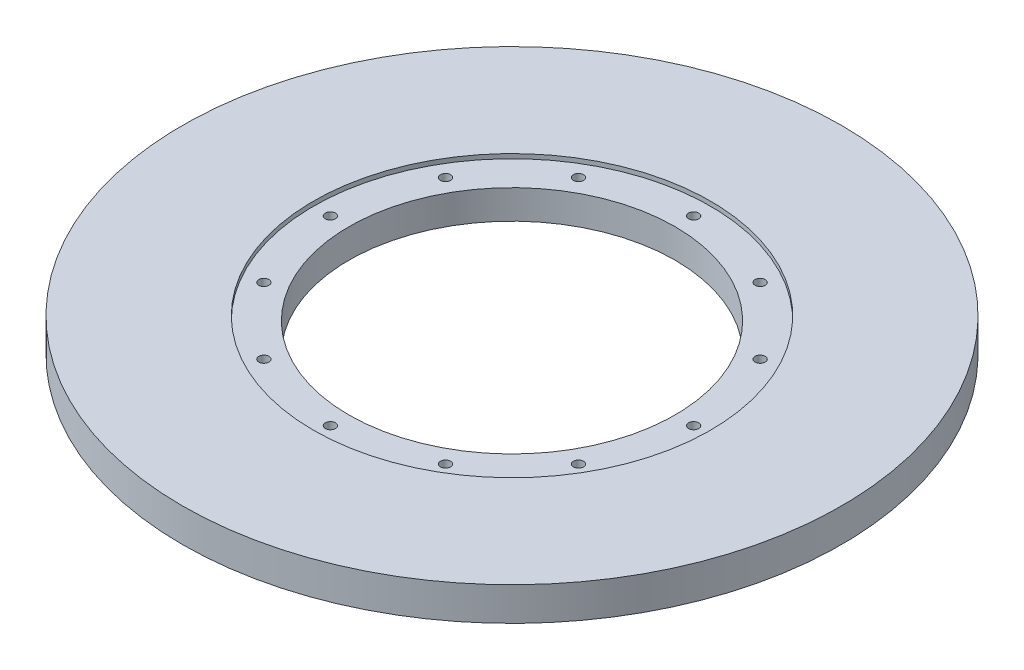
from build123d import *

# Parameters (mm, degrees)
SKETCH1_W           = 127.635
SKETCH1_H           = 127.635
BOSS_EXTRUDE1_DEPTH = 9.525
SKETCH13_R          = 93.6625
BOSS_EXTRUDE2_DEPTH = 9.525
SKETCH6_R           = 1.35255
F_6_32_HOLE1_DEPTH  = 12.7
SKETCH5_R           = 46.355
CUT_EXTRUDE1_DEPTH  = 9.525
SKETCH11_R          = 1.4351
CUT_EXTRUDE3_DEPTH  = 10.525
CIRPATTERN1_COUNT   = 12
SKETCH12_R          = 56.41975
CUT_EXTRUDE4_DEPTH  = 1.27


with BuildPart() as part:
    # Sketch1 → Boss-Extrude1 (new body)
    with BuildSketch(Plane(origin=(0, 0, 0), x_dir=(1, 0, 0), z_dir=(0, 1, 0))):
        with Locations((63.8175, 63.8175)):
            Rectangle(SKETCH1_W, SKETCH1_H)
    extrude(amount=BOSS_EXTRUDE1_DEPTH)

    # Sketch13 → Boss-Extrude2 (add)
    with BuildSketch(Plane(origin=(0, 9.525, 0), x_dir=(1, 0, 0), z_dir=(0, 1, 0))):
        with Locations((63.8175, 63.8175)):
            Circle(SKETCH13_R)
    extrude(amount=-BOSS_EXTRUDE2_DEPTH)

    # Sketch6 → 6-32 hole1 (cut)
    with BuildSketch(Plane(origin=(127.635, 0, 0), x_dir=(0, 0, -1), z_dir=(1, 0, 0))):
        with Locations((4.7625, 4.7625)):
            Circle(SKETCH6_R)
    extrude(amount=-F_6_32_HOLE1_DEPTH, mode=Mode.SUBTRACT)

    # Sketch5 → Cut-Extrude1 (cut)
    with BuildSketch(Plane(origin=(0, 9.525, 0), x_dir=(1, 0, 0), z_dir=(0, 1, 0))):
        with Locations((63.8175, 63.8175)):
            Circle(SKETCH5_R)
    extrude(amount=-CUT_EXTRUDE1_DEPTH, mode=Mode.SUBTRACT)

    # Sketch11 → Cut-Extrude3 (cut, through all)
    with BuildSketch(Plane(origin=(0, 9.525, 0), x_dir=(1, 0, 0), z_dir=(0, 1, 0))):
        with Locations((63.8175, 115.443)):
            Circle(SKETCH11_R)
    cut_extrude3 = extrude(amount=-CUT_EXTRUDE3_DEPTH, mode=Mode.SUBTRACT)

    # CirPattern1: Cut-Extrude3 ×12 about axis
    cirpattern1_axis = Axis((63.8175, 0, -63.8175), (0, 1, 0))
    for i in range(1, CIRPATTERN1_COUNT):
        add(cut_extrude3.rotate(cirpattern1_axis, i * 360 / CIRPATTERN1_COUNT), mode=Mode.SUBTRACT)

    # Sketch12 → Cut-Extrude4 (cut)
    with BuildSketch(Plane(origin=(0, 9.525, 0), x_dir=(1, 0, 0), z_dir=(0, 1, 0))):
        with Locations((63.8175, 63.8175)):
            Circle(SKETCH12_R)
    extrude(amount=-CUT_EXTRUDE4_DEPTH, mode=Mode.SUBTRACT)


solid = part.part
